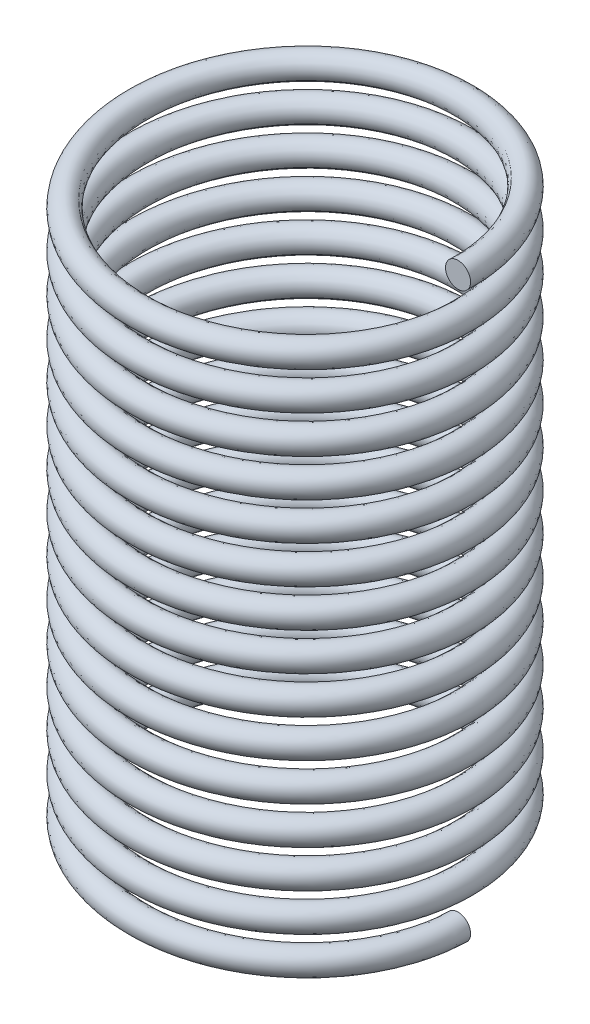
from build123d import *

# Parameters (mm, degrees)
SWEEP_1_PITCH       = 3
SWEEP_1_HEIGHT      = 45
SWEEP_1_RADIUS      = 13
SWEEP_1_START_ANGLE = 90
SKETCH_4_R          = 1


with BuildPart() as part:
    # 扫描1: sweep along a helix
    with BuildLine() as sweep_1_path:
        add(Helix(SWEEP_1_PITCH, SWEEP_1_HEIGHT, SWEEP_1_RADIUS, center=(0, 0, 0), direction=(0, 1, 0), lefthand=True, mode=Mode.PRIVATE).rotate(Axis((0, 0, 0), (0, 1, 0)), SWEEP_1_START_ANGLE))
    # 草图4 → 扫描1 (sweep)
    with BuildSketch(Plane.XY):
        with Locations((13, 45)):
            Circle(SKETCH_4_R)
    sweep(path=sweep_1_path.line, is_frenet=True)


solid = part.part
